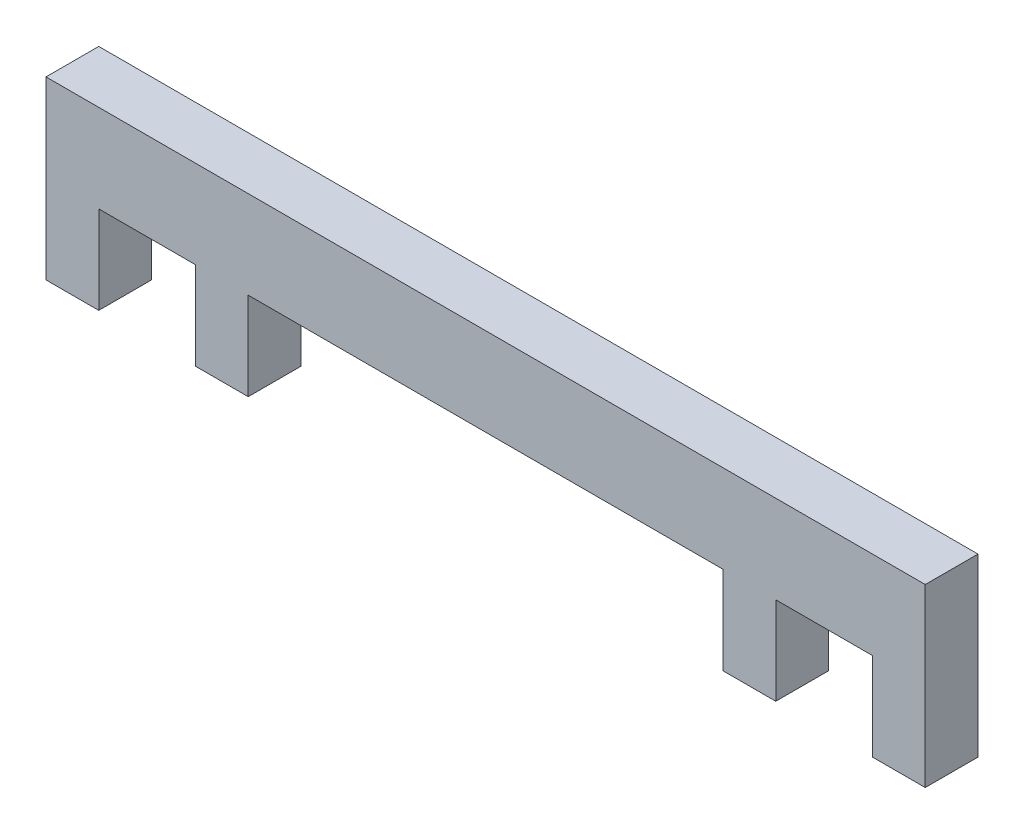
from build123d import *

# Parameters (mm, degrees)
EXTRUDE_1_DEPTH = 3


with BuildPart() as part:
    # ｽｹｯﾁ1 → ﾎﾞｽ - 押し出し1 (new body)
    with BuildSketch(Plane.XY):
        Polygon((0, 0), (-3, 0), (-3, 10), (47, 10), (47, 0), (44, 0), (44, 5), (38.5, 5), (38.5, 0), (35.5, 0), (35.5, 5), (8.5, 5), (8.5, 0), (5.5, 0), (5.5, 5), (0, 5), align=None)
    extrude(amount=EXTRUDE_1_DEPTH)


solid = part.part
